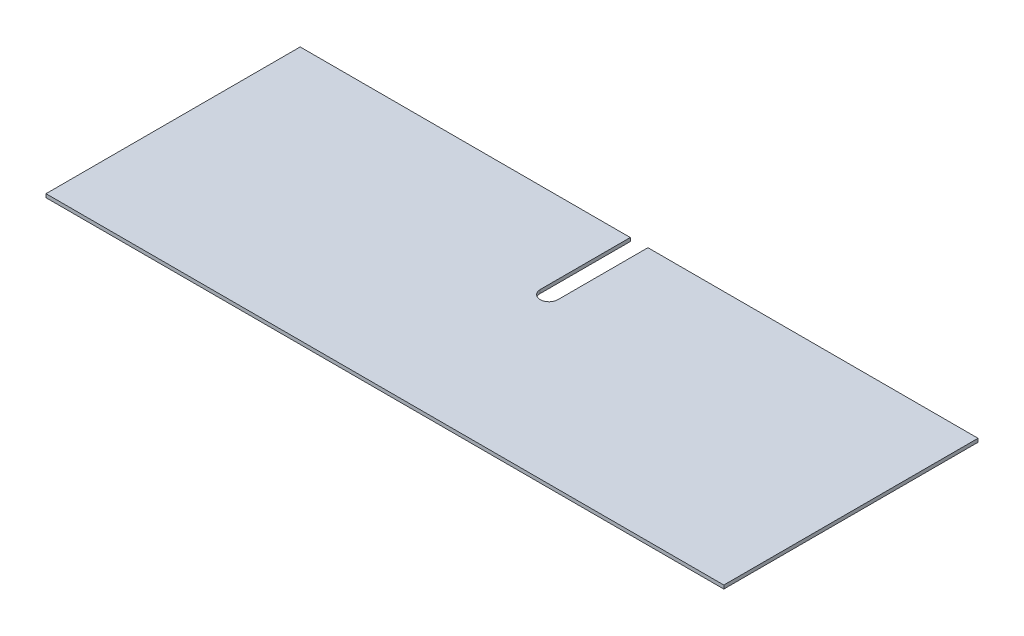
from build123d import *

# Parameters (mm, degrees)
SKETCH1_W           = 609.6
SKETCH1_H           = 228.6
BOSS_EXTRUDE1_DEPTH = 3.175
CUT_EXTRUDE1_DEPTH  = 4.175


with BuildPart() as part:
    # Sketch1 → Boss-Extrude1 (new body)
    with BuildSketch(Plane(origin=(0, 0, 0), x_dir=(1, 0, 0), z_dir=(0, 1, 0))):
        with Locations((304.8, 114.3)):
            Rectangle(SKETCH1_W, SKETCH1_H)
    extrude(amount=BOSS_EXTRUDE1_DEPTH)

    # Sketch2 → Cut-Extrude1 (cut, through all)
    with BuildSketch(Plane(origin=(0, 3.175, 0), x_dir=(1, 0, 0), z_dir=(0, 1, 0))):
        with BuildLine():
            Line((296.8625, 228.6), (312.7375, 228.6))
            Line((312.7375, 228.6), (312.7375, 147.6375))
            ThreePointArc((312.7375, 147.6375), (304.8, 139.7), (296.8625, 147.6375))
            Line((296.8625, 147.6375), (296.8625, 228.6))
        make_face()
    extrude(amount=-CUT_EXTRUDE1_DEPTH, mode=Mode.SUBTRACT)


solid = part.part
